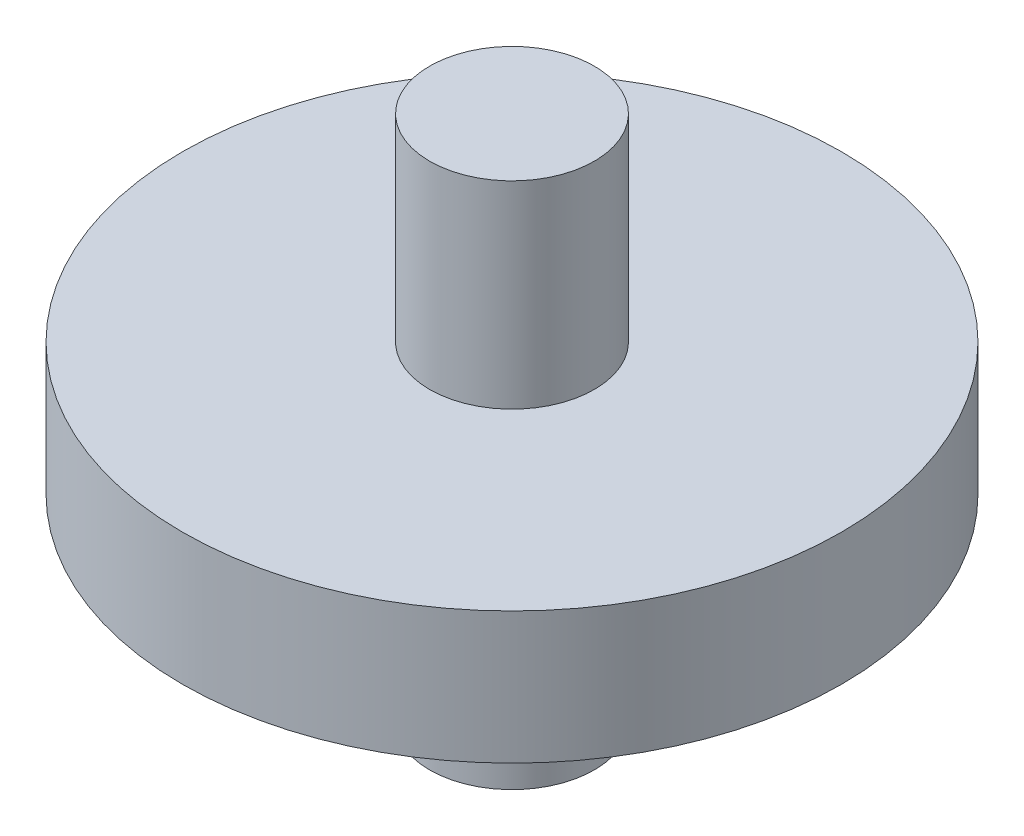
from build123d import *

# Parameters (mm, degrees)
ESBO_O2_R                     = 50
RESSALTO_EXTRUS_O1_DEPTH      = 20
ESBO_O3_R                     = 12.5
RESSALTO_EXTRUS_O2_DEPTH      = 40
RESSALTO_EXTRUS_O2_DEPTH_BACK = 40


with BuildPart() as part:
    # Esboço2 → Ressalto-extrusão1 (new body)
    with BuildSketch(Plane(origin=(0, 0, 0), x_dir=(1, 0, 0), z_dir=(0, 1, 0))):
        Circle(ESBO_O2_R)
    extrude(amount=RESSALTO_EXTRUS_O1_DEPTH)

    # Esboço3 → Ressalto-extrusão2 (add, two sides)
    with BuildSketch(Plane(origin=(0, 10, 0), x_dir=(1, 0, 0), z_dir=(0, 1, 0))) as ressalto_extrus_o2_sk:
        Circle(ESBO_O3_R)
    extrude(amount=RESSALTO_EXTRUS_O2_DEPTH)
    extrude(ressalto_extrus_o2_sk.sketch, amount=-RESSALTO_EXTRUS_O2_DEPTH_BACK)


solid = part.part
